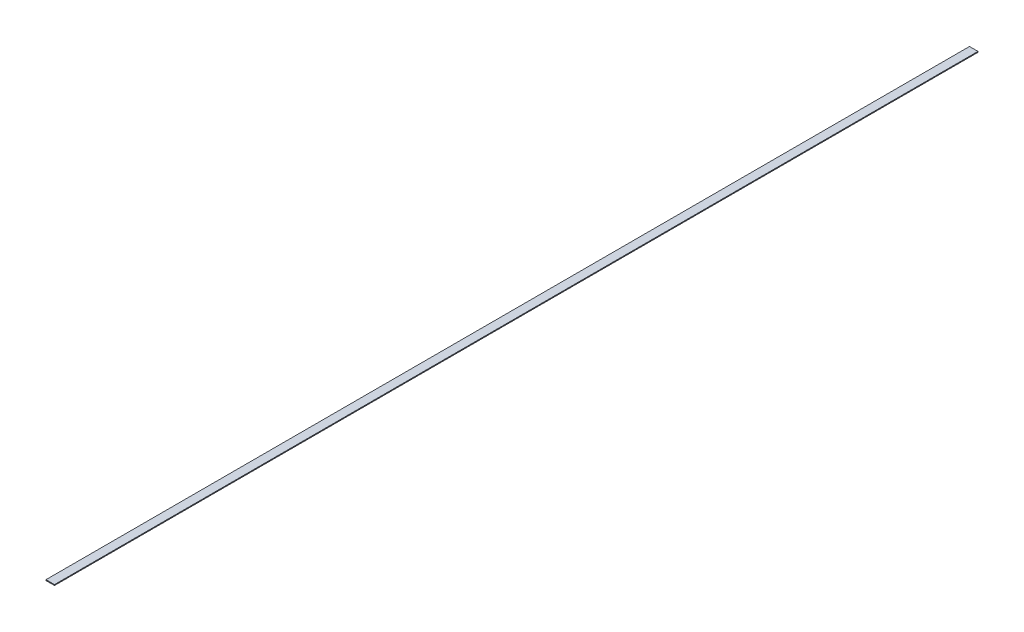
from build123d import *

# Parameters (mm, degrees)
SKETCH1_W           = 50.8
SKETCH1_H           = 5518.15
BOSS_EXTRUDE1_DEPTH = 5.08


with BuildPart() as part:
    # Sketch1 → Boss-Extrude1 (new body)
    with BuildSketch(Plane(origin=(0, 0, 0), x_dir=(1, 0, 0), z_dir=(0, 1, 0))):
        with Locations((25.4, 2759.075)):
            Rectangle(SKETCH1_W, SKETCH1_H)
    extrude(amount=BOSS_EXTRUDE1_DEPTH)


solid = part.part
